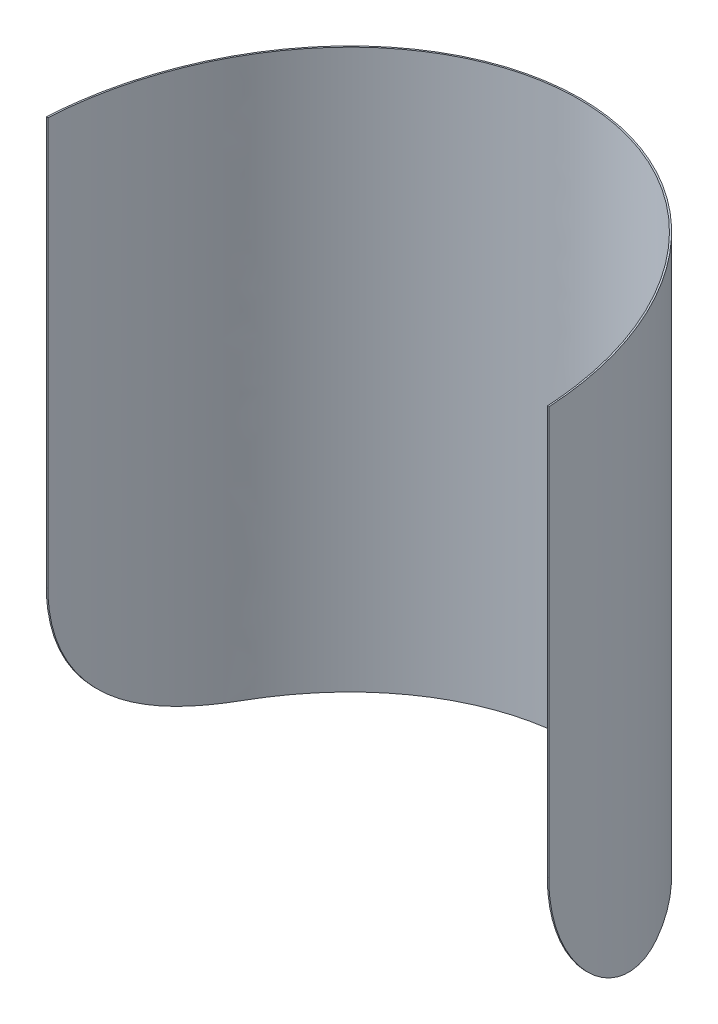
from build123d import *

# Parameters (mm, degrees)
BOSS_EXTRUDE1_DEPTH             = 185.25
SKETCH9_W                       = 200
SKETCH9_H                       = 6.6
CUT_EXTRUDE13_DEPTH             = 185.25
CUT_EXTRUDE14_REACH             = 85.319
CUT_EXTRUDE14_DIRECTION_2_REACH = 85.319


with BuildPart() as part:
    # Sketch1 → Boss-Extrude1 (new body)
    with BuildSketch(Plane(origin=(0, 0, 0), x_dir=(1, 0, 0), z_dir=(0, 1, 0))):
        with BuildLine():
            Line((-83, 0), (-83.5, 0))
            add(Edge.make_bspline(
                [(83.5, 0), (83.5, 6.551943238), (82.425529207, 19.725624534), (77.65164903, 38.675269098), (69.896900441, 56.158717698), (59.456164577, 71.486989113), (46.726061981, 84.07340283), (27.351064174, 96.559563604), (0, 103.126957597), (-27.351064174, 96.559563604), (-46.726061981, 84.07340283), (-59.456164577, 71.486989113), (-69.896900441, 56.158717698), (-77.65164903, 38.675269098), (-82.425529207, 19.725624534), (-83.5, 6.551943238), (-83.5, 0)],
                knots=[1.570796327, 1.570796327, 1.570796327, 1.570796327, 1.767145868, 1.963495408, 2.159844949, 2.35619449, 2.552544031, 2.748893572, 3.141592654, 3.534291735, 3.730641276, 3.926990817, 4.123340358, 4.319689899, 4.51603944, 4.71238898, 4.71238898, 4.71238898, 4.71238898], degree=3))
            Line((83.5, 0), (83, 0))
            add(Edge.make_bspline(
                [(83, 0), (83, 100), (0, 100), (-83, 100), (-83, 0)],
                knots=[1.570796327, 1.570796327, 1.570796327, 3.141592654, 3.141592654, 4.71238898, 4.71238898, 4.71238898], degree=2, weights=[1, 0.707106781, 1, 0.707106781, 1]))
        make_face()
    extrude(amount=-BOSS_EXTRUDE1_DEPTH)

    # Sketch9 → Cut-Extrude13 (cut)
    with BuildSketch(Plane(origin=(0, 0, 0), x_dir=(1, 0, 0), z_dir=(0, 1, 0))):
        with Locations((0, 3.3)):
            Rectangle(SKETCH9_W, SKETCH9_H)
    extrude(amount=-CUT_EXTRUDE13_DEPTH, mode=Mode.SUBTRACT)

    # Sketch2 → Cut-Extrude14 (cut, up to next)
    with BuildSketch(Plane(origin=(0, 0, 0), x_dir=(0, 0, -1), z_dir=(1, 0, 0)), mode=Mode.PRIVATE) as cut_extrude14_sk1:
        with BuildLine():
            Line((6.6, -185.25), (56.6, -185.25))
            ThreePointArc((56.6, -185.25), (21.244660941, -170.605339059), (6.6, -135.25))
            Line((6.6, -135.25), (6.6, -185.25))
        make_face()
    cut_extrude14_tool1 = extrude(cut_extrude14_sk1.sketch, amount=-CUT_EXTRUDE14_REACH, mode=Mode.PRIVATE) & part.part
    add(cut_extrude14_tool1.solids().sort_by_distance((0, -174.081603, -17.768397))[0], mode=Mode.SUBTRACT)

    # Sketch2 → Cut-Extrude14 direction 2 (cut, up to next)
    with BuildSketch(Plane(origin=(0, 0, 0), x_dir=(0, 0, -1), z_dir=(1, 0, 0)), mode=Mode.PRIVATE) as cut_extrude14_direction_2_sk1:
        with BuildLine():
            Line((6.6, -185.25), (56.6, -185.25))
            ThreePointArc((56.6, -185.25), (21.244660941, -170.605339059), (6.6, -135.25))
            Line((6.6, -135.25), (6.6, -185.25))
        make_face()
    cut_extrude14_direction_2_tool1 = extrude(cut_extrude14_direction_2_sk1.sketch, amount=CUT_EXTRUDE14_DIRECTION_2_REACH, mode=Mode.PRIVATE) & part.part
    add(cut_extrude14_direction_2_tool1.solids().sort_by_distance((0, -174.081603, -17.768397))[0], mode=Mode.SUBTRACT)


solid = part.part
